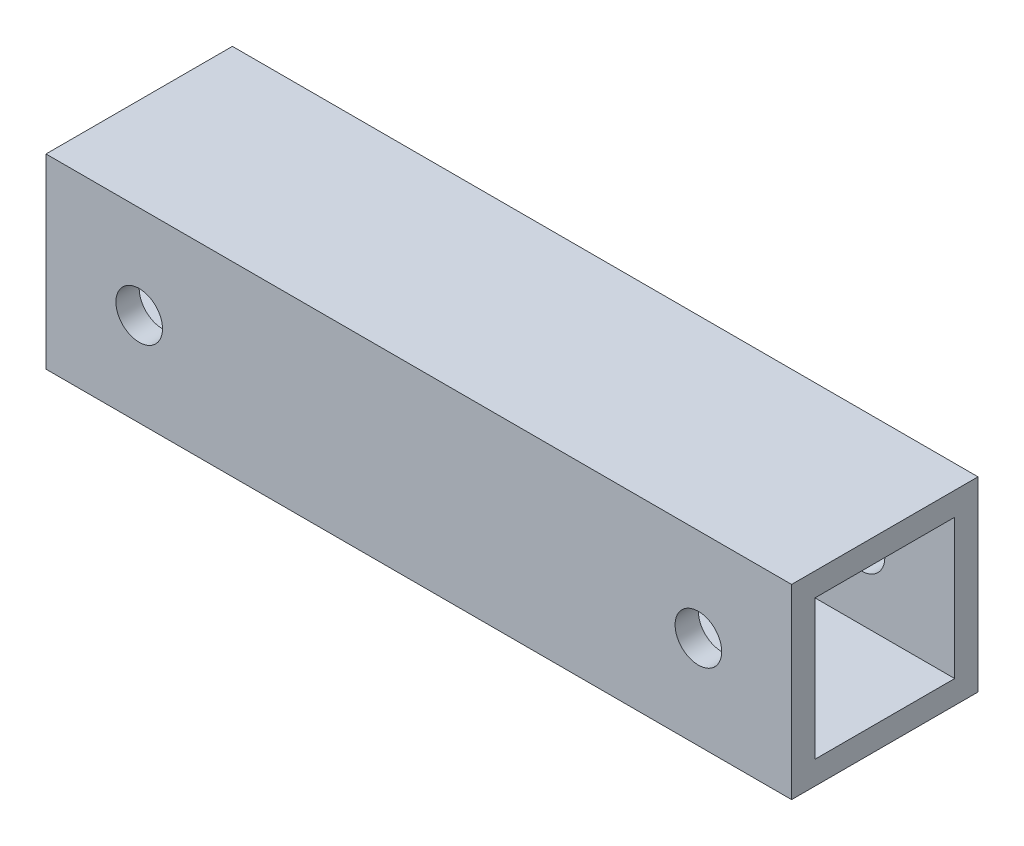
from build123d import *

# Parameters (mm, degrees)
SKETCH1_W           = 101.6
SKETCH1_H           = 25.4
BOSS_EXTRUDE1_DEPTH = 25.4
SKETCH2_W           = 9.525
SKETCH2_H           = 19.040717284
CUT_EXTRUDE1_DEPTH  = 508
SKETCH4_R           = 3.175
CUT_EXTRUDE3_DEPTH  = 508


with BuildPart() as part:
    # Sketch1 → Boss-Extrude1 (new body)
    with BuildSketch(Plane.XY):
        Rectangle(SKETCH1_W, SKETCH1_H)
    extrude(amount=BOSS_EXTRUDE1_DEPTH)

    # Sketch2 → Cut-Extrude1 (cut)
    with BuildSketch(Plane(origin=(50.8, 0, 0), x_dir=(0, 0, -1), z_dir=(1, 0, 0))):
        with Locations((-17.4625, 0)):
            Rectangle(SKETCH2_W, SKETCH2_H)
        with Locations((-7.9375, 0)):
            Rectangle(SKETCH2_W, SKETCH2_H)
    extrude(amount=-CUT_EXTRUDE1_DEPTH, mode=Mode.SUBTRACT)

    # Sketch4 → Cut-Extrude3 (cut)
    with BuildSketch(Plane.XY.offset(25.4)):
        with Locations((-38.1, 0)):
            Circle(SKETCH4_R)
        with Locations((38.1, 0)):
            Circle(SKETCH4_R)
    extrude(amount=-CUT_EXTRUDE3_DEPTH, mode=Mode.SUBTRACT)


solid = part.part
